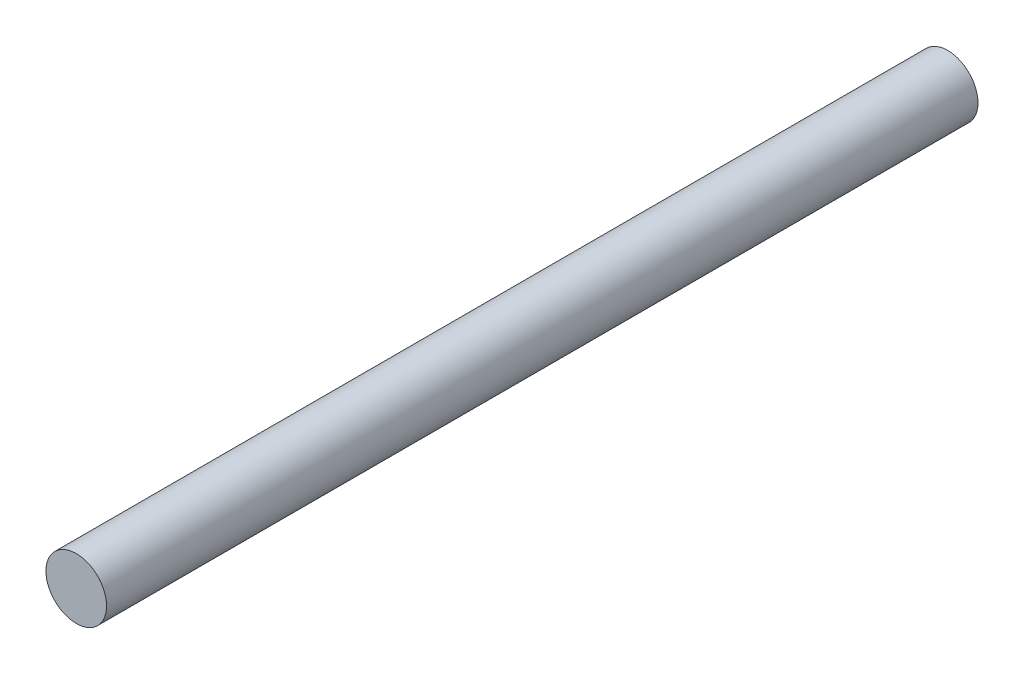
from build123d import *

# Parameters (mm, degrees)
SKETCH_1_R      = 6.260668565
EXTRUDE_1_DEPTH = 180


with BuildPart() as part:
    # 草图1 → 凸台-拉伸1 (new body)
    with BuildSketch(Plane.XY):
        Circle(SKETCH_1_R)
    extrude(amount=EXTRUDE_1_DEPTH)


solid = part.part
